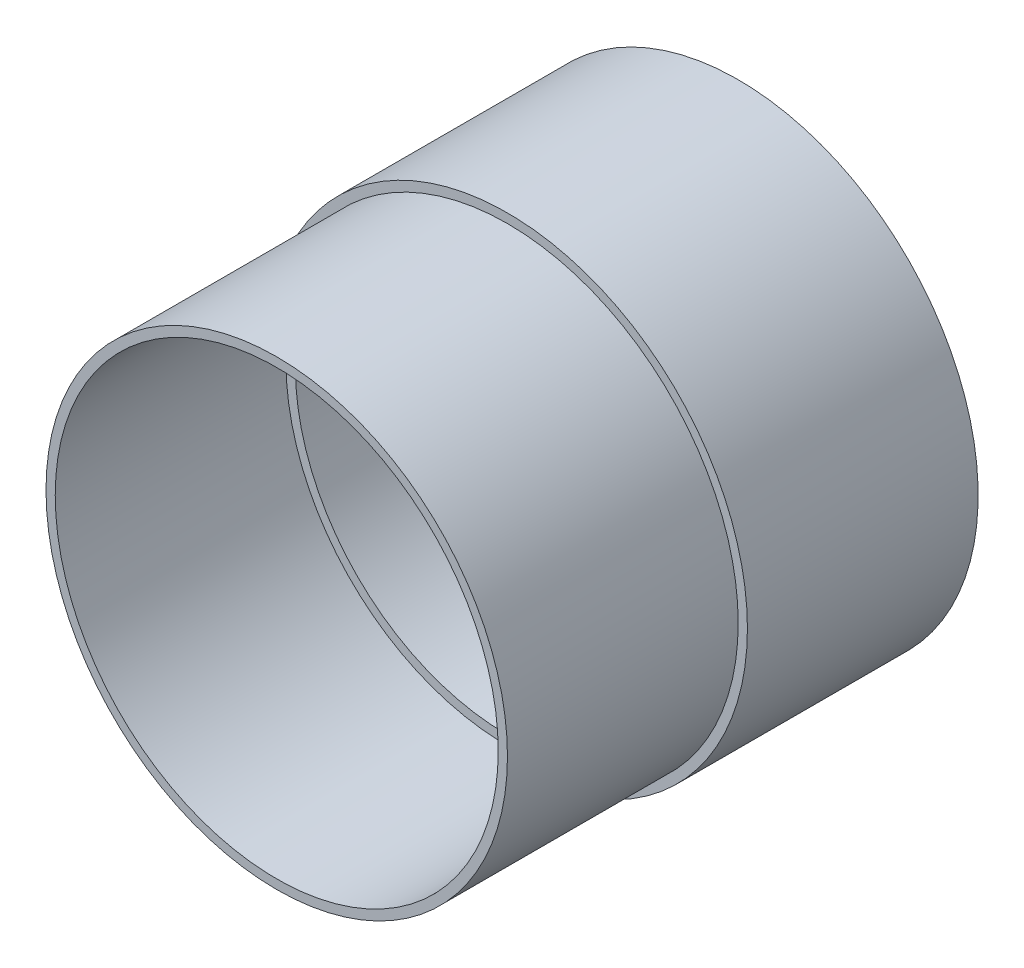
from build123d import *

# Parameters (mm, degrees)
CROQUIS1_R              = 50
SALIENTE_EXTRUIR1_DEPTH = 50
CROQUIS2_R              = 52
SALIENTE_EXTRUIR2_DEPTH = 10
CROQUIS3_R              = 48
CORTAR_EXTRUIR1_DEPTH   = 97
CROQUIS4_R              = 52
SALIENTE_EXTRUIR3_DEPTH = 47
CROQUIS5_R              = 45.966217712
CORTAR_EXTRUIR2_DEPTH   = 47


with BuildPart() as part:
    # Croquis1 → Saliente-Extruir1 (new body, symmetric)
    with BuildSketch(Plane.XY):
        with Locations((-84.01826484, 0)):
            Circle(CROQUIS1_R)
    extrude(amount=SALIENTE_EXTRUIR1_DEPTH, both=True)

    # Croquis2 → Saliente-Extruir2 (add)
    with BuildSketch(Plane(origin=(0, 0, -50), x_dir=(-1, 0, 0), z_dir=(0, 0, -1))):
        with Locations((84.01826484, 0)):
            Circle(CROQUIS2_R)
    extrude(amount=-SALIENTE_EXTRUIR2_DEPTH)

    # Croquis3 → Cortar-Extruir1 (cut)
    with BuildSketch(Plane.XY.offset(50)):
        with Locations((-84.01826484, 0)):
            Circle(CROQUIS3_R)
    extrude(amount=-CORTAR_EXTRUIR1_DEPTH, mode=Mode.SUBTRACT)

    # Croquis4 → Saliente-Extruir3 (add)
    with BuildSketch(Plane.XY):
        with Locations((-84.01826484, 0)):
            Circle(CROQUIS4_R)
    extrude(amount=-SALIENTE_EXTRUIR3_DEPTH)

    # Croquis5 → Cortar-Extruir2 (cut)
    with BuildSketch(Plane.XY):
        with Locations((-84.01826484, 0)):
            Circle(CROQUIS5_R)
    extrude(amount=-CORTAR_EXTRUIR2_DEPTH, mode=Mode.SUBTRACT)


solid = part.part
